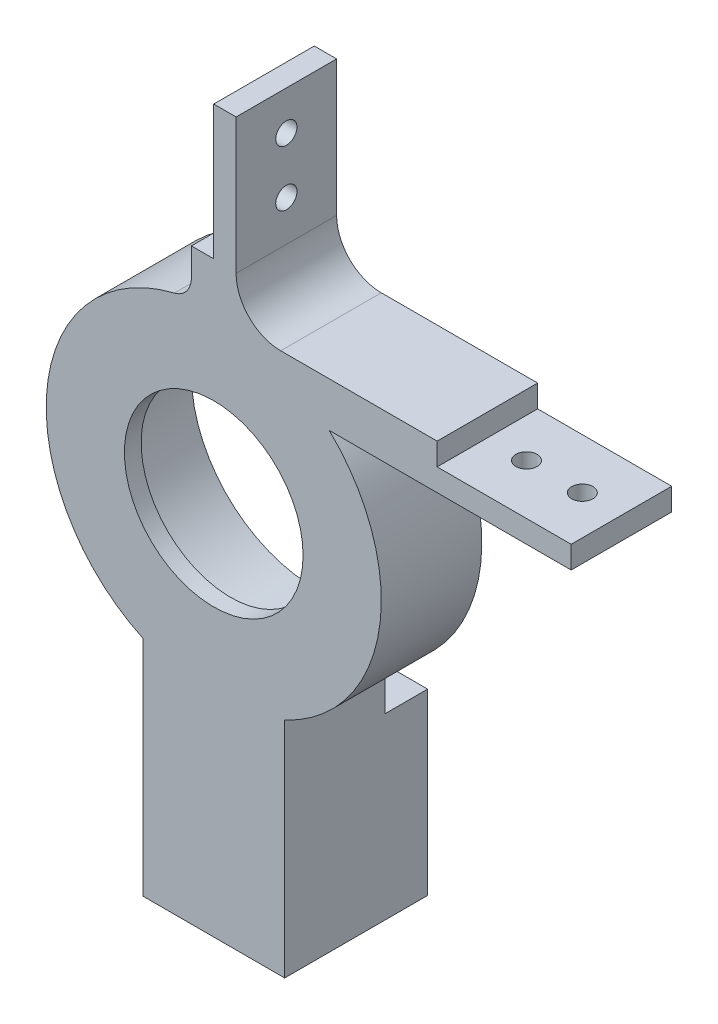
from build123d import *

# Parameters (mm, degrees)
SKETCH2_R           = 15
SKETCH2_R_2         = 11
BOSS_EXTRUDE1_DEPTH = 9
BOSS_EXTRUDE2_DEPTH = 9
SKETCH4_W           = 12.7
SKETCH4_H           = 16
BOSS_EXTRUDE3_DEPTH = 3.8
SKETCH5_R           = 1.275
CUT_EXTRUDE1_DEPTH  = 7
SKETCH6_R           = 11
SKETCH6_R_2         = 8
BOSS_EXTRUDE4_DEPTH = 1.5
BOSS_EXTRUDE5_DEPTH = 9
SKETCH8_W           = 12
SKETCH8_H           = 2
SKETCH8_W_2         = 2
SKETCH8_H_2         = 12
CUT_EXTRUDE2_DEPTH  = 13.8
CUT_EXTRUDE3_REACH  = 34
SKETCH9_R           = 0.95
CUT_EXTRUDE4_REACH  = 48.456
SKETCH10_R          = 0.95
FILLET1_R           = 4
FILLET3_R           = 2
SKETCH11_R          = 11
BOSS_EXTRUDE6_DEPTH = 1.5
SKETCH13_R          = 0.95
CUT_EXTRUDE5_DEPTH  = 9
FILLET2_R           = 1


with BuildPart() as part:
    # Sketch2 → Boss-Extrude1 (new body)
    with BuildSketch(Plane.XY):
        Circle(SKETCH2_R)
        Circle(SKETCH2_R_2, mode=Mode.SUBTRACT)
    extrude(amount=BOSS_EXTRUDE1_DEPTH)

    # Sketch3 → Boss-Extrude2 (add)
    with BuildSketch(Plane.XY):
        with BuildLine():
            Line((-6.35, -13.589610002), (-6.35, -33.589610002))
            Line((-6.35, -33.589610002), (6.35, -33.589610002))
            Line((6.35, -33.589610002), (6.35, -13.589610002))
            ThreePointArc((6.35, -13.589610002), (0, -15), (-6.35, -13.589610002))
        make_face()
    extrude(amount=BOSS_EXTRUDE2_DEPTH)

    # Sketch4 → Boss-Extrude3 (add)
    with BuildSketch(Plane.XY):
        with Locations((0, -25.589610002)):
            Rectangle(SKETCH4_W, SKETCH4_H)
    extrude(amount=-BOSS_EXTRUDE3_DEPTH)

    # Sketch5 → Cut-Extrude1 (cut)
    with BuildSketch(Plane.XZ.offset(33.589610002)):
        with Locations((0, 2.6)):
            Circle(SKETCH5_R)
    extrude(amount=-CUT_EXTRUDE1_DEPTH, mode=Mode.SUBTRACT)

    # Sketch6 → Boss-Extrude4 (add)
    with BuildSketch(Plane.XY.offset(9)):
        Circle(SKETCH6_R)
        Circle(SKETCH6_R_2, mode=Mode.SUBTRACT)
    extrude(amount=-BOSS_EXTRUDE4_DEPTH)

    # Sketch7 → Boss-Extrude5 (add)
    with BuildSketch(Plane.XY):
        Polygon((-2, 14.866068747), (2, 10.866068747), (32, 10.866068747), (32, 14.866068747), (2, 14.866068747), (2, 31), (-2, 31), align=None)
    extrude(amount=BOSS_EXTRUDE5_DEPTH)

    # Sketch8 → Cut-Extrude2 (cut, through all)
    with BuildSketch(Plane.XY.offset(9)):
        with Locations((26, 13.866068747)):
            Rectangle(SKETCH8_W, SKETCH8_H)
        with Locations((-1, 25)):
            Rectangle(SKETCH8_W_2, SKETCH8_H_2)
    extrude(amount=-CUT_EXTRUDE2_DEPTH, mode=Mode.SUBTRACT)

    # Sketch9 → Cut-Extrude3 (cut, up to next)
    with BuildSketch(Plane.ZY, mode=Mode.PRIVATE) as cut_extrude3_sk1:
        with Locations((4.5, 27.5)):
            Circle(SKETCH9_R)
    cut_extrude3_tool1 = extrude(cut_extrude3_sk1.sketch, amount=-CUT_EXTRUDE3_REACH, mode=Mode.PRIVATE) & part.part
    add(cut_extrude3_tool1.solids().sort_by_distance((0, 27.5, 4.5))[0], mode=Mode.SUBTRACT)
    # Sketch9 → Cut-Extrude3 (cut, up to next)
    with BuildSketch(Plane.ZY, mode=Mode.PRIVATE) as cut_extrude3_sk2:
        with Locations((4.5, 22.5)):
            Circle(SKETCH9_R)
    cut_extrude3_tool2 = extrude(cut_extrude3_sk2.sketch, amount=-CUT_EXTRUDE3_REACH, mode=Mode.PRIVATE) & part.part
    add(cut_extrude3_tool2.solids().sort_by_distance((0, 22.5, 4.5))[0], mode=Mode.SUBTRACT)

    # Sketch10 → Cut-Extrude4 (cut, up to next)
    with BuildSketch(Plane(origin=(0, 12.866068747, 0), x_dir=(1, 0, 0), z_dir=(0, 1, 0)), mode=Mode.PRIVATE) as cut_extrude4_sk1:
        with Locations((23.5, -4.5)):
            Circle(SKETCH10_R)
    cut_extrude4_tool1 = extrude(cut_extrude4_sk1.sketch, amount=-CUT_EXTRUDE4_REACH, mode=Mode.PRIVATE) & part.part
    add(cut_extrude4_tool1.solids().sort_by_distance((23.5, 12.866069, 4.5))[0], mode=Mode.SUBTRACT)
    # Sketch10 → Cut-Extrude4 (cut, up to next)
    with BuildSketch(Plane(origin=(0, 12.866068747, 0), x_dir=(1, 0, 0), z_dir=(0, 1, 0)), mode=Mode.PRIVATE) as cut_extrude4_sk2:
        with Locations((28.5, -4.5)):
            Circle(SKETCH10_R)
    cut_extrude4_tool2 = extrude(cut_extrude4_sk2.sketch, amount=-CUT_EXTRUDE4_REACH, mode=Mode.PRIVATE) & part.part
    add(cut_extrude4_tool2.solids().sort_by_distance((28.5, 12.866069, 4.5))[0], mode=Mode.SUBTRACT)

    # Fillet1
    fillet1_edges = [part.edges().sort_by_distance(p)[0] for p in [
        (2, 14.866068747, 4.5),
    ]]
    fillet(fillet1_edges, radius=FILLET1_R)

    # Fillet3
    fillet3_edges = [part.edges().sort_by_distance(p)[0] for p in [
        (-2, 14.866068747, 4.5),
    ]]
    fillet(fillet3_edges, radius=FILLET3_R)


with BuildPart() as body_2:
    # Sketch11 → Boss-Extrude6 (new body)
    with BuildSketch(Plane(origin=(0, 0, 0), x_dir=(-1, 0, 0), z_dir=(0, 0, -1))):
        with BuildLine():
            Line((-6, 14.866068747), (-10.340626189, 10.866068747))
            ThreePointArc((-10.340626189, 10.866068747), (-14.804198945, -2.415718027), (-6.35, -13.589610002))
            Line((-6.35, -13.589610002), (-6.35, -17.589610002))
            Line((-6.35, -17.589610002), (6.35, -17.589610002))
            Line((6.35, -17.589610002), (6.35, -13.589610002))
            ThreePointArc((6.35, -13.589610002), (14.92536147, 1.49451831), (3.529411765, 14.578863213))
            ThreePointArc((3.529411765, 14.578863213), (2.428189504, 15.286017757), (2, 16.522711642))
            Line((2, 16.522711642), (2, 19))
            Line((2, 19), (0, 19))
            Line((0, 19), (-2, 19))
            Line((-2, 19), (-2, 18.866068747))
            ThreePointArc((-2, 18.866068747), (-3.171572875, 16.037641623), (-6, 14.866068747))
        make_face()
        Circle(SKETCH11_R, mode=Mode.SUBTRACT)
    extrude(amount=BOSS_EXTRUDE6_DEPTH)


with BuildPart() as cut_extrude5_tool:
    # Sketch13 → Cut-Extrude5 (new body)
    with BuildSketch(Plane(origin=(0, 0, -1.5), x_dir=(-1, 0, 0), z_dir=(0, 0, -1))):
        with Locations((0, 15)):
            Circle(SKETCH13_R)
        with Locations((0, -15)):
            Circle(SKETCH13_R)
    extrude(amount=-CUT_EXTRUDE5_DEPTH)


with BuildPart() as part_1:
    add(part.part)

    # Cut-Extrude5: cut by cut_extrude5_tool
    add(cut_extrude5_tool.part, mode=Mode.SUBTRACT)


with BuildPart() as body_2_1:
    add(body_2.part)

    # Cut-Extrude5: cut by cut_extrude5_tool
    add(cut_extrude5_tool.part, mode=Mode.SUBTRACT)

    # Fillet2
    fillet2_edges = [body_2_1.edges().sort_by_distance(p)[0] for p in [
        (0, 19, -1.5),
    ]]
    fillet(fillet2_edges, radius=FILLET2_R)


solid = part_1.part
